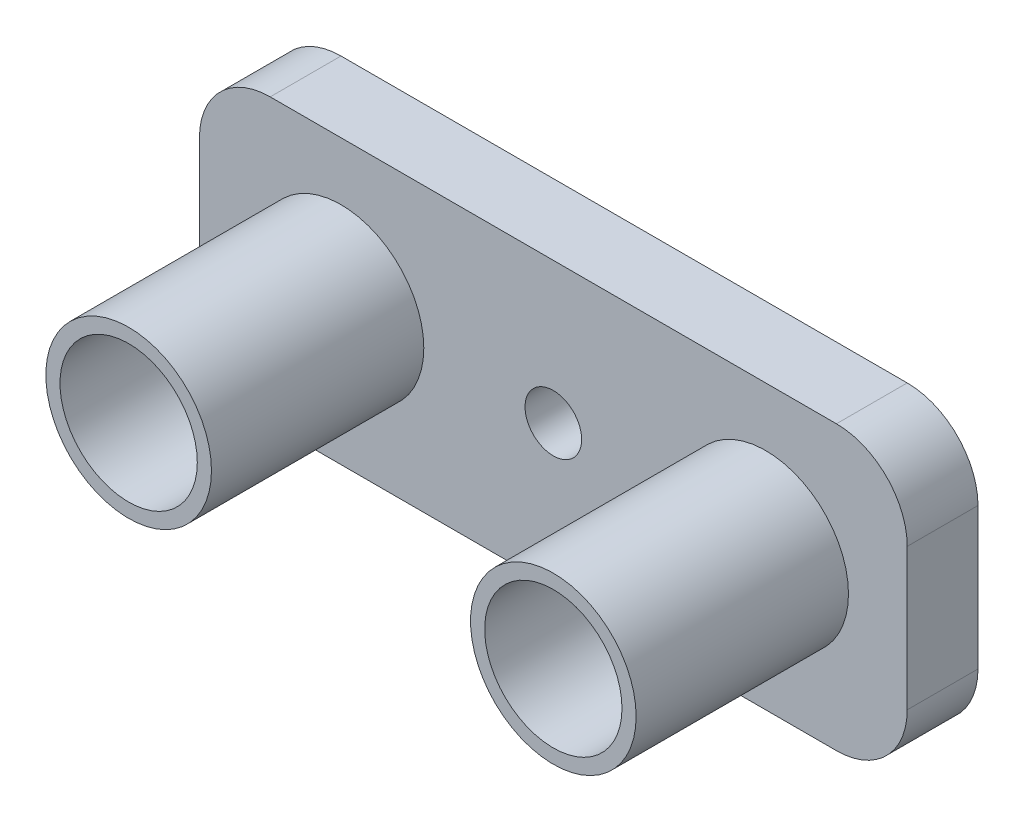
from build123d import *

# Parameters (mm, degrees)
SKETCH1_R           = 2
BOSS_EXTRUDE1_DEPTH = 5
SKETCH1_4_R         = 5.85
SKETCH1_4_R_2       = 4.85
EXTRUDE_THIN1_DEPTH = 20


with BuildPart() as part:
    # Sketch1 → Boss-Extrude1 (new body)
    with BuildSketch(Plane.XY):
        with BuildLine():
            Line((2.96969697, 19.045454545), (42.96969697, 19.045454545))
            ThreePointArc((42.96969697, 19.045454545), (46.505230876, 17.580988451), (47.96969697, 14.045454545))
            Line((47.96969697, 14.045454545), (47.96969697, 4.045454545))
            ThreePointArc((47.96969697, 4.045454545), (46.505230876, 0.50992064), (42.96969697, -0.954545455))
            Line((42.96969697, -0.954545455), (3.116761061, -0.954545455))
            ThreePointArc((3.116761061, -0.954545455), (-0.522762861, 0.552994715), (-2.03030303, 4.192518637))
            Line((-2.03030303, 4.192518637), (-2.03030303, 14.045454545))
            ThreePointArc((-2.03030303, 14.045454545), (-0.565836936, 17.580988451), (2.96969697, 19.045454545))
        make_face()
        with Locations((22.96969697, 9.082220568)):
            Circle(SKETCH1_R, mode=Mode.SUBTRACT)
    extrude(amount=BOSS_EXTRUDE1_DEPTH)

    # Sketch1_4 → Extrude-Thin1 (add)
    with BuildSketch(Plane.XY):
        with Locations((7.969686156, 9.104280198)):
            Circle(SKETCH1_4_R)
        with Locations((7.969686156, 9.104280198)):
            Circle(SKETCH1_4_R_2, mode=Mode.SUBTRACT)
        with Locations((37.96969697, 9.060160955)):
            Circle(SKETCH1_4_R)
        with Locations((37.96969697, 9.060160955)):
            Circle(SKETCH1_4_R_2, mode=Mode.SUBTRACT)
    extrude(amount=EXTRUDE_THIN1_DEPTH)


solid = part.part
